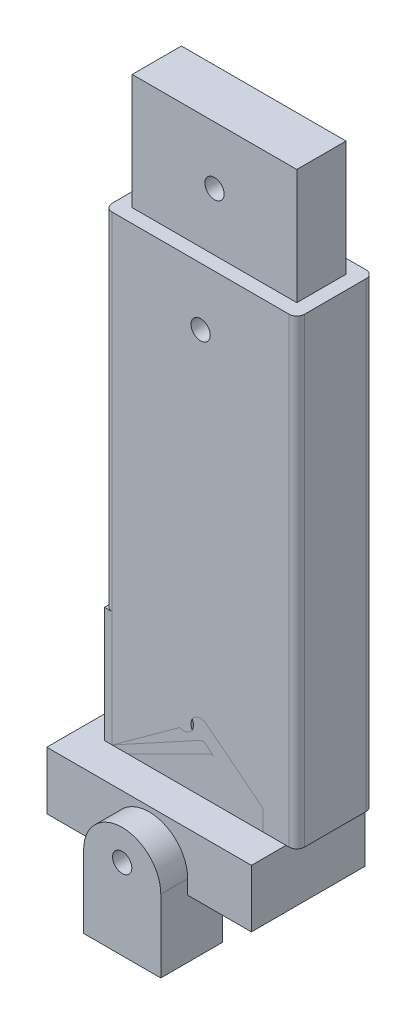
from build123d import *

# Parameters (mm, degrees)
BOSS_EXTRUDE1_DEPTH      = 120
SKETCH3_W                = 42
SKETCH3_H                = 12
CUT_EXTRUDE2_DEPTH       = 30
SKETCH6_R                = 2.5
CUT_EXTRUDE3_DEPTH       = 30
SKETCH8_W                = 42.8
SKETCH8_H                = 12.8
BOSS_EXTRUDE2_DEPTH      = 30
SKETCH9_R                = 2.5
CUT_EXTRUDE4_DEPTH       = 30
SKETCH11_W               = 41.2
SKETCH11_H               = 11.5
BOSS_EXTRUDE3_DEPTH      = 30
BOSS_EXTRUDE4_DEPTH      = 3
BOSS_EXTRUDE4_DEPTH_BACK = 14.5
SKETCH16_W               = 41.2
SKETCH16_H               = 17.5
BOSS_EXTRUDE5_DEPTH      = 15
CUT_EXTRUDE5_DEPTH       = 3.12
BOSS_EXTRUDE6_DEPTH      = 16
SKETCH25_R               = 6.975
CUT_EXTRUDE6_DEPTH       = 12
SKETCH29_R               = 2.5
CUT_EXTRUDE8_DEPTH       = 17


with BuildPart() as part:
    # Sketch1 → Boss-Extrude1 (new body)
    with BuildSketch(Plane(origin=(0, 0, 0), x_dir=(1, 0, 0), z_dir=(0, 1, 0))):
        with BuildLine():
            Line((2, 0), (48, 0))
            ThreePointArc((48, 0), (49.414213562, 0.585786438), (50, 2))
            Line((50, 2), (50, 18))
            ThreePointArc((50, 18), (49.414213562, 19.414213562), (48, 20))
            Line((48, 20), (2, 20))
            ThreePointArc((2, 20), (0.585786438, 19.414213562), (0, 18))
            Line((0, 18), (0, 2))
            ThreePointArc((0, 2), (0.585786438, 0.585786438), (2, 0))
        make_face()
    extrude(amount=BOSS_EXTRUDE1_DEPTH)

    # Sketch3 → Cut-Extrude2 (cut)
    with BuildSketch(Plane.XZ):
        with Locations((25, -10)):
            Rectangle(SKETCH3_W, SKETCH3_H)
    extrude(amount=-CUT_EXTRUDE2_DEPTH, mode=Mode.SUBTRACT)

    # Sketch6 → Cut-Extrude3 (cut)
    with BuildSketch(Plane.XY):
        with Locations((25, 105)):
            Circle(SKETCH6_R)
        with Locations((25, 15)):
            Circle(SKETCH6_R)
    extrude(amount=-CUT_EXTRUDE3_DEPTH, mode=Mode.SUBTRACT)

    # Sketch8 → Boss-Extrude2 (add)
    with BuildSketch(Plane(origin=(0, 120, 0), x_dir=(1, 0, 0), z_dir=(0, 1, 0))):
        with Locations((25, 10)):
            Rectangle(SKETCH8_W, SKETCH8_H)
    extrude(amount=BOSS_EXTRUDE2_DEPTH)

    # Sketch9 → Cut-Extrude4 (cut)
    with BuildSketch(Plane.XY.offset(-3.6)):
        with Locations((25, 135)):
            Circle(SKETCH9_R)
    extrude(amount=-CUT_EXTRUDE4_DEPTH, mode=Mode.SUBTRACT)


with BuildPart() as body_2:
    # Sketch11 → Boss-Extrude3 (new body)
    with BuildSketch(Plane(origin=(0, 0, 0), x_dir=(1, 0, 0), z_dir=(0, 1, 0))):
        with Locations((20.6, 5.75)):
            Rectangle(SKETCH11_W, SKETCH11_H)
    extrude(amount=BOSS_EXTRUDE3_DEPTH)

    # Sketch13 → Ø5.0 (5) Diameter Hole1 (revolve, cut)
    with BuildSketch(Plane(origin=(20.6, 15, 0), x_dir=(0, -1, 0), z_dir=(1, 0, 0))):
        Polygon((0, 0), (0, 20), (2.5, 20), (2.5, 0.020977491), (2.525, 0), align=None)
    revolve(axis=Axis((20.6, 15, 6.35), (0, 0, -1)), mode=Mode.SUBTRACT)

    # Sketch15 → Boss-Extrude4 (add, two sides)
    with BuildSketch(Plane.XY) as boss_extrude4_sk:
        with BuildLine():
            Line((0, 0), (0, -15.109741722))
            ThreePointArc((0, -15.109741722), (20.6, -1.159826197), (41.2, -15.109741722))
            Line((41.2, -15.109741722), (41.2, 0))
            Line((41.2, 0), (0, 0))
        make_face()
    extrude(amount=BOSS_EXTRUDE4_DEPTH)
    extrude(boss_extrude4_sk.sketch, amount=-BOSS_EXTRUDE4_DEPTH_BACK)

    # Sketch16 → Boss-Extrude5 (add)
    with BuildSketch(Plane(origin=(0, 0, 0), x_dir=(1, 0, 0), z_dir=(0, 1, 0))):
        Polygon((-6, 20.5), (-6, 11.5), (-6, 0), (-6, -9), (47.2, -9), (47.2, 0), (47.2, 11.5), (47.2, 20.5), align=None)
        with Locations((20.6, 5.75)):
            Rectangle(SKETCH16_W, SKETCH16_H, mode=Mode.SUBTRACT)
    extrude(amount=-BOSS_EXTRUDE5_DEPTH)

    # Sketch18 → Ø5.0 (5) Diameter Hole2 (revolve, cut)
    with BuildSketch(Plane(origin=(20.6, -9.147025383, -20.5), x_dir=(0, 1, 0), z_dir=(1, 0, 0))):
        Polygon((0, 0), (0, 29.5), (2.5, 29.5), (2.5, 0.020977491), (2.525, 0), align=None)
    revolve(axis=Axis((20.6, -9.147025383, -26.85), (0, 0, 1)), mode=Mode.SUBTRACT)

    # Sketch22 → Cut-Extrude5 (cut)
    with BuildSketch(Plane.XY.offset(9)):
        Polygon((24.013806249, -11.026766561), (23.934806737, -7.130453037), (20.521000488, -5.250711859), (17.186193751, -7.267284205), (17.265193263, -11.163597729), (20.678999512, -13.043338907), align=None)
    extrude(amount=-CUT_EXTRUDE5_DEPTH, mode=Mode.SUBTRACT)


with BuildPart() as body_3:
    # Sketch24 → Boss-Extrude6 (new body)
    with BuildSketch(Plane.XY):
        with BuildLine():
            Line((10.573788764, -11.282332988), (10.573788764, -30.158964502))
            Line((10.573788764, -30.158964502), (30.631278849, -30.158964502))
            Line((30.631278849, -30.158964502), (30.631278849, -11.282332988))
            ThreePointArc((30.631278849, -11.282332988), (20.602533806, -1.253587945), (10.573788764, -11.282332988))
        make_face()
    extrude(amount=BOSS_EXTRUDE6_DEPTH)

    # Sketch25 → Cut-Extrude6 (cut)
    with BuildSketch(Plane.XZ.offset(30.158964502)):
        with Locations((20.602549742, 7.999999594)):
            Circle(SKETCH25_R)
    extrude(amount=-CUT_EXTRUDE6_DEPTH, mode=Mode.SUBTRACT)

    # Sketch29 → Cut-Extrude8 (cut, through all)
    with BuildSketch(Plane(origin=(0, 0, 0), x_dir=(-1, 0, 0), z_dir=(0, 0, -1))):
        with Locations((-20.6, -9.147025383)):
            Circle(SKETCH29_R)
    extrude(amount=-CUT_EXTRUDE8_DEPTH, mode=Mode.SUBTRACT)


solid = Compound([part.part, body_2.part, body_3.part])
